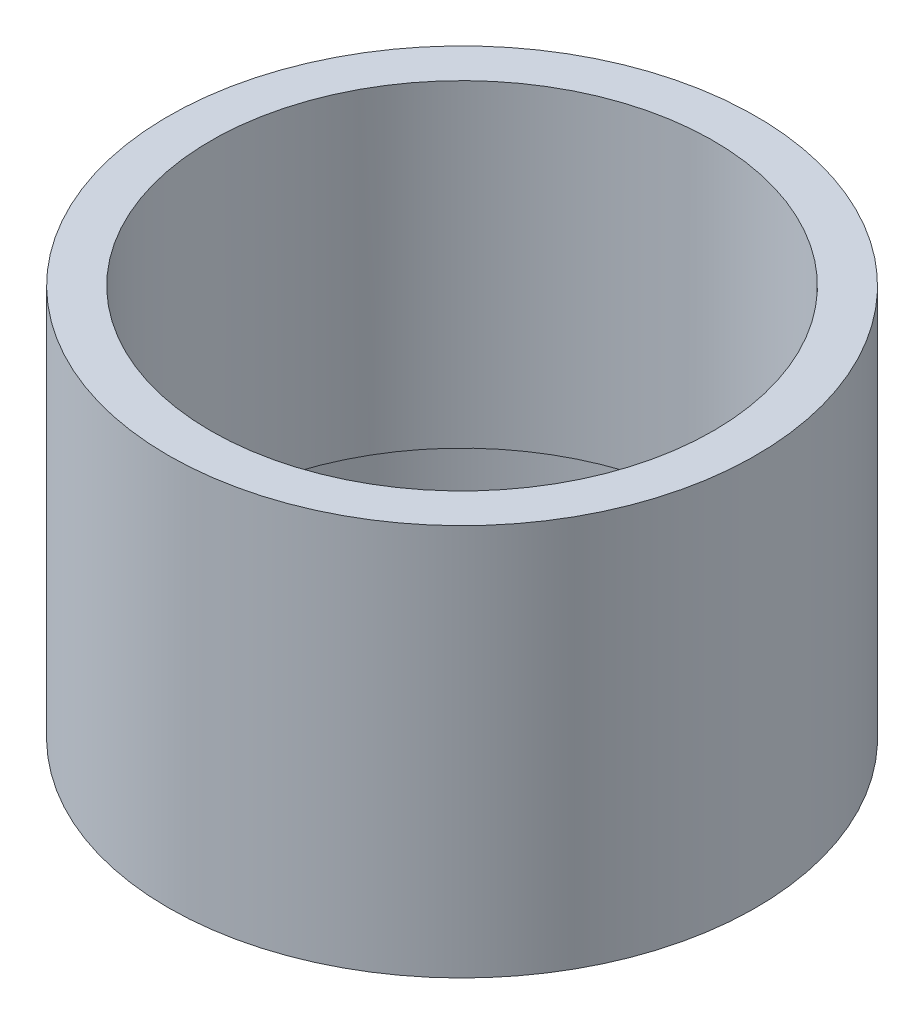
from build123d import *

# Parameters (mm, degrees)
SKETCH1_R           = 38.1
SKETCH1_R_2         = 33.0835
BOSS_EXTRUDE1_DEPTH = 9.525
SKETCH2_R           = 38.1
SKETCH2_R_2         = 15.875
BOSS_EXTRUDE2_DEPTH = 3.175
SKETCH4_R           = 38.1
SKETCH4_R_2         = 32.5882
BOSS_EXTRUDE3_DEPTH = 38.1


with BuildPart() as part:
    # Sketch1 → Boss-Extrude1 (new body)
    with BuildSketch(Plane(origin=(0, 0, 0), x_dir=(1, 0, 0), z_dir=(0, 1, 0))):
        Circle(SKETCH1_R)
        Circle(SKETCH1_R_2, mode=Mode.SUBTRACT)
    extrude(amount=-BOSS_EXTRUDE1_DEPTH)

    # Sketch2 → Boss-Extrude2 (add)
    with BuildSketch(Plane(origin=(0, 0, 0), x_dir=(1, 0, 0), z_dir=(0, 1, 0))):
        Circle(SKETCH2_R)
        Circle(SKETCH2_R_2, mode=Mode.SUBTRACT)
        with BuildLine():
            Line((-1.5875, 29.025074125), (-1.5875, 21.708736001))
            ThreePointArc((-1.5875, 21.708736001), (-2.288559931, 19.718699434), (-4.082142857, 18.607488001))
            ThreePointArc((-4.082142857, 18.607488001), (-16.497783942, 9.525), (-18.155628738, -5.768504584))
            ThreePointArc((-18.155628738, -5.768504584), (-18.221174605, -7.877398679), (-19.594066861, -9.479552672))
            Line((-19.594066861, -9.479552672), (-25.930201539, -13.137721734))
            ThreePointArc((-25.930201539, -13.137721734), (-28.585844638, -13.378023404), (-30.488092465, -11.509430788))
            ThreePointArc((-30.488092465, -11.509430788), (-28.222209064, 16.2941), (-5.276586788, 32.158177982))
            ThreePointArc((-5.276586788, 32.158177982), (-2.707214199, 31.445079348), (-1.5875, 29.025074125))
        make_face(mode=Mode.SUBTRACT)
        with BuildLine():
            Line((1.5875, 29.025074125), (1.5875, 21.708736001))
            ThreePointArc((1.5875, 21.708736001), (2.288559931, 19.718699434), (4.082142857, 18.607488001))
            ThreePointArc((4.082142857, 18.607488001), (16.497783942, 9.525), (18.155628738, -5.768504584))
            ThreePointArc((18.155628738, -5.768504584), (18.221174605, -7.877398679), (19.594066861, -9.479552672))
            Line((19.594066861, -9.479552672), (25.930201539, -13.137721734))
            ThreePointArc((25.930201539, -13.137721734), (28.585844638, -13.378023404), (30.488092465, -11.509430788))
            ThreePointArc((30.488092465, -11.509430788), (28.222209064, 16.2941), (5.276586788, 32.158177982))
            ThreePointArc((5.276586788, 32.158177982), (2.707214199, 31.445079348), (1.5875, 29.025074125))
        make_face(mode=Mode.SUBTRACT)
        with BuildLine():
            Line((24.342701539, -15.887352391), (18.006566861, -12.229183329))
            ThreePointArc((18.006566861, -12.229183329), (15.932614674, -11.841300756), (14.073485881, -12.838983416))
            ThreePointArc((14.073485881, -12.838983416), (0, -19.05), (-14.073485881, -12.838983416))
            ThreePointArc((-14.073485881, -12.838983416), (-15.932614674, -11.841300756), (-18.006566861, -12.229183329))
            Line((-18.006566861, -12.229183329), (-24.342701539, -15.887352391))
            ThreePointArc((-24.342701539, -15.887352391), (-25.87863044, -18.067055943), (-25.211505678, -20.648747194))
            ThreePointArc((-25.211505678, -20.648747194), (0, -32.5882), (25.211505678, -20.648747194))
            ThreePointArc((25.211505678, -20.648747194), (25.87863044, -18.067055943), (24.342701539, -15.887352391))
        make_face(mode=Mode.SUBTRACT)
    extrude(amount=BOSS_EXTRUDE2_DEPTH)

    # Sketch4 → Boss-Extrude3 (add)
    with BuildSketch(Plane(origin=(0, 3.175, 0), x_dir=(1, 0, 0), z_dir=(0, 1, 0))):
        Circle(SKETCH4_R)
        Circle(SKETCH4_R_2, mode=Mode.SUBTRACT)
    extrude(amount=BOSS_EXTRUDE3_DEPTH)


solid = part.part
